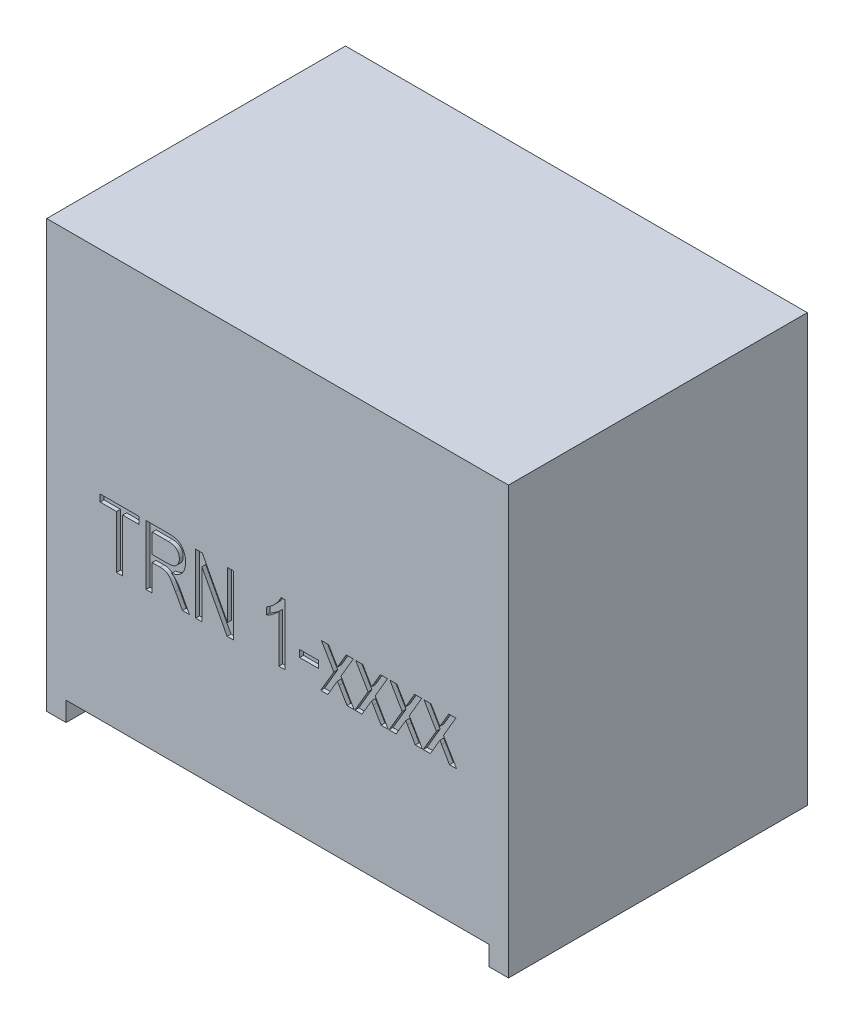
from build123d import *

# Parameters (mm, degrees)
SKETCH1_W           = 11.9
SKETCH1_H           = 7.7
BOSS_EXTRUDE1_DEPTH = 11
SKETCH2_W           = 10.9
SKETCH2_H           = 7.7
CUT_EXTRUDE1_DEPTH  = 0.5
SKETCH3_W           = 0.480308949
SKETCH3_H           = 0.180115856
CUT_EXTRUDE2_DEPTH  = 0.1


with BuildPart() as part:
    # Sketch1 → Boss-Extrude1 (new body)
    with BuildSketch(Plane(origin=(0, 0, 0), x_dir=(1, 0, 0), z_dir=(0, 1, 0))):
        Rectangle(SKETCH1_W, SKETCH1_H)
    extrude(amount=BOSS_EXTRUDE1_DEPTH)

    # Sketch2 → Cut-Extrude1 (cut)
    with BuildSketch(Plane.XZ):
        Rectangle(SKETCH2_W, SKETCH2_H)
    extrude(amount=-CUT_EXTRUDE1_DEPTH, mode=Mode.SUBTRACT)

    # Sketch3 → Cut-Extrude2 (cut)
    with BuildSketch(Plane.XY.offset(3.85)):
        Polygon((-4.15267112, 4), (-4.15267112, 5.360875355), (-4.572941451, 5.360875355), (-4.572941451, 5.540991211), (-3.572297807, 5.540991211), (-3.572297807, 5.360875355), (-3.992568137, 5.360875355), (-3.992568137, 4), align=None)
        with BuildLine():
            Line((-3.392181951, 4), (-3.392181951, 5.540991211))
            Line((-3.392181951, 5.540991211), (-2.826192891, 5.540991211))
            add(Edge.make_bspline(
                [(-2.826192891, 5.540991211), (-2.811909521, 5.540908994), (-2.784262589, 5.540749855), (-2.744212003, 5.53846055), (-2.706971218, 5.535071655), (-2.67258985, 5.530565745), (-2.641268608, 5.524318773), (-2.61288328, 5.516740747), (-2.58720294, 5.508282085), (-2.557055192, 5.494329446), (-2.522660431, 5.47268752), (-2.485565707, 5.439714952), (-2.453073753, 5.398882682), (-2.424160732, 5.351968017), (-2.400416466, 5.299293955), (-2.383597341, 5.241849691), (-2.373443966, 5.180389971), (-2.372176068, 5.138063351), (-2.371525435, 5.116343065)],
                knots=[0, 0, 0, 0, 4.2845e-05, 8.293e-05, 0.0001203, 0.000155016, 0.000186905, 0.000216032, 0.000243127, 0.000267893, 0.000315525, 0.000364475, 0.000416047, 0.000471502, 0.000529446, 0.00058881, 0.000650602, 0.000715735, 0.000715735, 0.000715735, 0.000715735], degree=3))
            add(Edge.make_bspline(
                [(-2.371525435, 5.116343065), (-2.371865621, 5.101949587), (-2.372530111, 5.073834626), (-2.376555412, 5.032627277), (-2.383550456, 4.993539941), (-2.394248174, 4.956673759), (-2.406654905, 4.921570608), (-2.42294654, 4.888845826), (-2.441638087, 4.858076771), (-2.463362969, 4.829508008), (-2.487663047, 4.803203242), (-2.51493482, 4.779575951), (-2.544648016, 4.758290638), (-2.577034315, 4.739534199), (-2.611893281, 4.723066546), (-2.649637248, 4.709926058), (-2.689677967, 4.698418589), (-2.717529709, 4.693140372), (-2.731757147, 4.690444114)],
                knots=[0, 0, 0, 0, 4.3181e-05, 8.4346e-05, 0.00012409, 0.000162103, 0.000199399, 0.00023562, 0.000271552, 0.000307263, 0.000343107, 0.00037879, 0.000415322, 0.000452597, 0.000490926, 0.000530787, 0.000572366, 0.000615785, 0.000615785, 0.000615785, 0.000615785], degree=3))
            add(Edge.make_bspline(
                [(-2.731757147, 4.690444114), (-2.721255851, 4.684634001), (-2.701265458, 4.673573802), (-2.673907877, 4.655729229), (-2.650527684, 4.637767787), (-2.637310644, 4.624697022), (-2.63106738, 4.618522852)],
                knots=[0, 0, 0, 0, 3.5993e-05, 6.8517e-05, 9.7918e-05, 0.000124239, 0.000124239, 0.000124239, 0.000124239], degree=3))
            add(Edge.make_bspline(
                [(-2.63106738, 4.618522852), (-2.618579993, 4.603450075), (-2.5934648, 4.573135028), (-2.559035867, 4.524771172), (-2.526057484, 4.474459234), (-2.506691025, 4.439067379), (-2.496918592, 4.421208434)],
                knots=[0, 0, 0, 0, 5.8701e-05, 0.000118063, 0.000177998, 0.000239047, 0.000239047, 0.000239047, 0.000239047], degree=3))
            Line((-2.496918592, 4.421208434), (-2.271461071, 4))
            Line((-2.271461071, 4), (-2.453453133, 4))
            Line((-2.453453133, 4), (-2.631380081, 4.329587))
            add(Edge.make_bspline(
                [(-2.631380081, 4.329587), (-2.639668725, 4.345040901), (-2.655522922, 4.374600523), (-2.679052196, 4.416570829), (-2.700924303, 4.454421826), (-2.721102307, 4.488190431), (-2.739885237, 4.517518395), (-2.756755043, 4.542808724), (-2.77220465, 4.563773414), (-2.790695385, 4.585373376), (-2.812187859, 4.607763946), (-2.837737185, 4.630251097), (-2.863256837, 4.647683593), (-2.88923934, 4.660959002), (-2.917840496, 4.669704449), (-2.950068369, 4.676250528), (-2.987364534, 4.679811101), (-3.013806661, 4.68021998), (-3.027885125, 4.680437678)],
                knots=[0, 0, 0, 0, 5.2608e-05, 0.000100627, 0.000144339, 0.000183756, 0.000218627, 0.000248809, 0.000274951, 0.000296692, 0.000334066, 0.000367983, 0.000398599, 0.000426568, 0.000455148, 0.000488018, 0.000525107, 0.000567341, 0.000567341, 0.000567341, 0.000567341], degree=3))
            Line((-3.027885125, 4.680437678), (-3.232078968, 4.680437678))
            Line((-3.232078968, 4.680437678), (-3.232078968, 4))
            Line((-3.232078968, 4), (-3.392181951, 4))
        make_face()
        with BuildLine():
            Line((-3.232078968, 4.860553533), (-2.856524901, 4.860553533))
            add(Edge.make_bspline(
                [(-2.856524901, 4.860553533), (-2.837231632, 4.860929368), (-2.801074164, 4.861633719), (-2.750489876, 4.866311627), (-2.707314738, 4.874776879), (-2.670742278, 4.887106132), (-2.639556463, 4.903442809), (-2.612405126, 4.923673225), (-2.588589828, 4.947834166), (-2.568332374, 4.975780714), (-2.551582938, 5.006902563), (-2.540278421, 5.041114427), (-2.532605368, 5.077435514), (-2.53195937, 5.102542399), (-2.531628418, 5.115404961)],
                knots=[0, 0, 0, 0, 5.788e-05, 0.000108473, 0.000152199, 0.000189579, 0.000223848, 0.00025737, 0.000290759, 0.000325221, 0.000360612, 0.00039631, 0.000432983, 0.000471508, 0.000471508, 0.000471508, 0.000471508], degree=3))
            add(Edge.make_bspline(
                [(-2.531628418, 5.115404961), (-2.531917464, 5.124687828), (-2.532480966, 5.142785019), (-2.535445791, 5.169223287), (-2.541232254, 5.194102417), (-2.548867136, 5.217556101), (-2.559131789, 5.239370066), (-2.571118478, 5.259888646), (-2.586214328, 5.278268245), (-2.602642133, 5.295668237), (-2.621653665, 5.311115457), (-2.642884506, 5.324500125), (-2.666330374, 5.33574349), (-2.691766171, 5.34538421), (-2.71970815, 5.351796883), (-2.749501459, 5.357350941), (-2.781516457, 5.360430175), (-2.803568231, 5.360723929), (-2.81493565, 5.360875355)],
                knots=[0, 0, 0, 0, 2.7858e-05, 5.4311e-05, 7.9647e-05, 0.000104369, 0.000128152, 0.000151856, 0.000175444, 0.000199328, 0.000223552, 0.00024871, 0.000274443, 0.000301453, 0.000330121, 0.0003603, 0.000392348, 0.000426445, 0.000426445, 0.000426445, 0.000426445], degree=3))
            Line((-2.81493565, 5.360875355), (-3.232078968, 5.360875355))
            Line((-3.232078968, 5.360875355), (-3.232078968, 4.860553533))
        make_face(mode=Mode.SUBTRACT)
        Polygon((-2.111358088, 4), (-2.111358088, 5.540991211), (-1.940935967, 5.540991211), (-1.2908303, 4.312701139), (-1.2908303, 5.540991211), (-1.130727317, 5.540991211), (-1.130727317, 4), (-1.302087541, 4), (-1.951255105, 5.226726567), (-1.951255105, 4), align=None)
        with BuildLine():
            Line((0.190122292, 4), (0.030019309, 4))
            Line((0.030019309, 4), (0.030019309, 5.220785245))
            add(Edge.make_bspline(
                [(0.030019309, 5.220785245), (0.020186801, 5.209467184), (-0.000191064, 5.186010515), (-0.035565991, 5.152651862), (-0.074987439, 5.118252286), (-0.118632216, 5.084872544), (-0.163102769, 5.052900153), (-0.207025705, 5.024779879), (-0.248754812, 5.00031312), (-0.276749153, 4.987014306), (-0.290186657, 4.980630771)],
                knots=[0, 0, 0, 0, 4.4952e-05, 9.3163e-05, 0.000145701, 0.000201869, 0.000257922, 0.000309966, 0.000358293, 0.000402904, 0.000402904, 0.000402904, 0.000402904], degree=3))
            Line((-0.290186657, 4.980630771), (-0.290186657, 5.160746626))
            add(Edge.make_bspline(
                [(-0.290186657, 5.160746626), (-0.268591504, 5.173743411), (-0.225586112, 5.199625693), (-0.16532993, 5.244462163), (-0.108406693, 5.29285576), (-0.056517823, 5.345313543), (-0.010057039, 5.399389663), (0.02982132, 5.453357698), (0.062519048, 5.506644244), (0.078558331, 5.543299241), (0.086305514, 5.561004084)],
                knots=[0, 0, 0, 0, 7.5573e-05, 0.0001505, 0.000225016, 0.000299531, 0.000371605, 0.000438715, 0.000500708, 0.000558628, 0.000558628, 0.000558628, 0.000558628], degree=3))
            Line((0.086305514, 5.561004084), (0.190122292, 5.561004084))
            Line((0.190122292, 5.561004084), (0.190122292, 4))
        make_face()
        with Locations((0.810521352, 4.550354004)):
            Rectangle(SKETCH3_W, SKETCH3_H)
        with BuildLine():
            Line((1.110714444, 4), (1.449057076, 4.577246302))
            Line((1.449057076, 4.577246302), (1.130727317, 5.120720881))
            Line((1.130727317, 5.120720881), (1.313970184, 5.120720881))
            Line((1.313970184, 5.120720881), (1.467193742, 4.85961543))
            add(Edge.make_bspline(
                [(1.467193742, 4.85961543), (1.473944953, 4.848031384), (1.486979035, 4.825666888), (1.506353969, 4.793322332), (1.523888188, 4.762820419), (1.53544809, 4.743279631), (1.540991211, 4.733909572)],
                knots=[0, 0, 0, 0, 4.0223e-05, 7.7656e-05, 0.000113107, 0.000145768, 0.000145768, 0.000145768, 0.000145768], degree=3))
            add(Edge.make_bspline(
                [(1.540991211, 4.733909572), (1.552982751, 4.754232399), (1.575730413, 4.792784313), (1.598427738, 4.831365884), (1.609160059, 4.849608994)],
                knots=[0, 0, 0, 0, 7.0791e-05, 0.000134288, 0.000134288, 0.000134288, 0.000134288], degree=3))
            Line((1.609160059, 4.849608994), (1.768012238, 5.120720881))
            Line((1.768012238, 5.120720881), (1.951255105, 5.120720881))
            Line((1.951255105, 5.120720881), (1.632925346, 4.577246302))
            Line((1.632925346, 4.577246302), (1.971267978, 4))
            Line((1.971267978, 4), (1.787712409, 4))
            Line((1.787712409, 4), (1.583518566, 4.348349068))
            Line((1.583518566, 4.348349068), (1.540991211, 4.420895733))
            Line((1.540991211, 4.420895733), (1.294270013, 4))
            Line((1.294270013, 4), (1.110714444, 4))
        make_face()
        with BuildLine():
            Line((1.99128085, 4), (2.329623482, 4.577246302))
            Line((2.329623482, 4.577246302), (2.011293723, 5.120720881))
            Line((2.011293723, 5.120720881), (2.194536591, 5.120720881))
            Line((2.194536591, 5.120720881), (2.347760148, 4.85961543))
            add(Edge.make_bspline(
                [(2.347760148, 4.85961543), (2.354511359, 4.848031384), (2.367545442, 4.825666888), (2.386920375, 4.793322332), (2.404454594, 4.762820419), (2.416014496, 4.743279631), (2.421557617, 4.733909572)],
                knots=[0, 0, 0, 0, 4.0223e-05, 7.7656e-05, 0.000113107, 0.000145768, 0.000145768, 0.000145768, 0.000145768], degree=3))
            add(Edge.make_bspline(
                [(2.421557617, 4.733909572), (2.433549157, 4.754232399), (2.45629682, 4.792784313), (2.478994145, 4.831365884), (2.489726465, 4.849608994)],
                knots=[0, 0, 0, 0, 7.0791e-05, 0.000134288, 0.000134288, 0.000134288, 0.000134288], degree=3))
            Line((2.489726465, 4.849608994), (2.648578644, 5.120720881))
            Line((2.648578644, 5.120720881), (2.831821511, 5.120720881))
            Line((2.831821511, 5.120720881), (2.513491752, 4.577246302))
            Line((2.513491752, 4.577246302), (2.851834384, 4))
            Line((2.851834384, 4), (2.668278816, 4))
            Line((2.668278816, 4), (2.464084972, 4.348349068))
            Line((2.464084972, 4.348349068), (2.421557617, 4.420895733))
            Line((2.421557617, 4.420895733), (2.174836419, 4))
            Line((2.174836419, 4), (1.99128085, 4))
        make_face()
        with BuildLine():
            Line((2.871847257, 4), (3.210189889, 4.577246302))
            Line((3.210189889, 4.577246302), (2.89186013, 5.120720881))
            Line((2.89186013, 5.120720881), (3.075102997, 5.120720881))
            Line((3.075102997, 5.120720881), (3.228326555, 4.85961543))
            add(Edge.make_bspline(
                [(3.228326555, 4.85961543), (3.235077765, 4.848031384), (3.248111848, 4.825666888), (3.267486781, 4.793322332), (3.285021, 4.762820419), (3.296580902, 4.743279631), (3.302124023, 4.733909572)],
                knots=[0, 0, 0, 0, 4.0223e-05, 7.7656e-05, 0.000113107, 0.000145768, 0.000145768, 0.000145768, 0.000145768], degree=3))
            add(Edge.make_bspline(
                [(3.302124023, 4.733909572), (3.314115563, 4.754232399), (3.336863226, 4.792784313), (3.359560551, 4.831365884), (3.370292872, 4.849608994)],
                knots=[0, 0, 0, 0, 7.0791e-05, 0.000134288, 0.000134288, 0.000134288, 0.000134288], degree=3))
            Line((3.370292872, 4.849608994), (3.52914505, 5.120720881))
            Line((3.52914505, 5.120720881), (3.712387917, 5.120720881))
            Line((3.712387917, 5.120720881), (3.394058158, 4.577246302))
            Line((3.394058158, 4.577246302), (3.73240079, 4))
            Line((3.73240079, 4), (3.548845222, 4))
            Line((3.548845222, 4), (3.344651378, 4.348349068))
            Line((3.344651378, 4.348349068), (3.302124023, 4.420895733))
            Line((3.302124023, 4.420895733), (3.055402825, 4))
            Line((3.055402825, 4), (2.871847257, 4))
        make_face()
        with BuildLine():
            Line((3.752413663, 4), (4.090756295, 4.577246302))
            Line((4.090756295, 4.577246302), (3.772426536, 5.120720881))
            Line((3.772426536, 5.120720881), (3.955669403, 5.120720881))
            Line((3.955669403, 5.120720881), (4.108892961, 4.85961543))
            add(Edge.make_bspline(
                [(4.108892961, 4.85961543), (4.115644171, 4.848031384), (4.128678254, 4.825666888), (4.148053188, 4.793322332), (4.165587406, 4.762820419), (4.177147308, 4.743279631), (4.18269043, 4.733909572)],
                knots=[0, 0, 0, 0, 4.0223e-05, 7.7656e-05, 0.000113107, 0.000145768, 0.000145768, 0.000145768, 0.000145768], degree=3))
            add(Edge.make_bspline(
                [(4.18269043, 4.733909572), (4.194681969, 4.754232399), (4.217429632, 4.792784313), (4.240126957, 4.831365884), (4.250859278, 4.849608994)],
                knots=[0, 0, 0, 0, 7.0791e-05, 0.000134288, 0.000134288, 0.000134288, 0.000134288], degree=3))
            Line((4.250859278, 4.849608994), (4.409711456, 5.120720881))
            Line((4.409711456, 5.120720881), (4.592954324, 5.120720881))
            Line((4.592954324, 5.120720881), (4.274624564, 4.577246302))
            Line((4.274624564, 4.577246302), (4.612967196, 4))
            Line((4.612967196, 4), (4.429411628, 4))
            Line((4.429411628, 4), (4.225217785, 4.348349068))
            Line((4.225217785, 4.348349068), (4.18269043, 4.420895733))
            Line((4.18269043, 4.420895733), (3.935969231, 4))
            Line((3.935969231, 4), (3.752413663, 4))
        make_face()
    extrude(amount=-CUT_EXTRUDE2_DEPTH, mode=Mode.SUBTRACT)


solid = part.part
